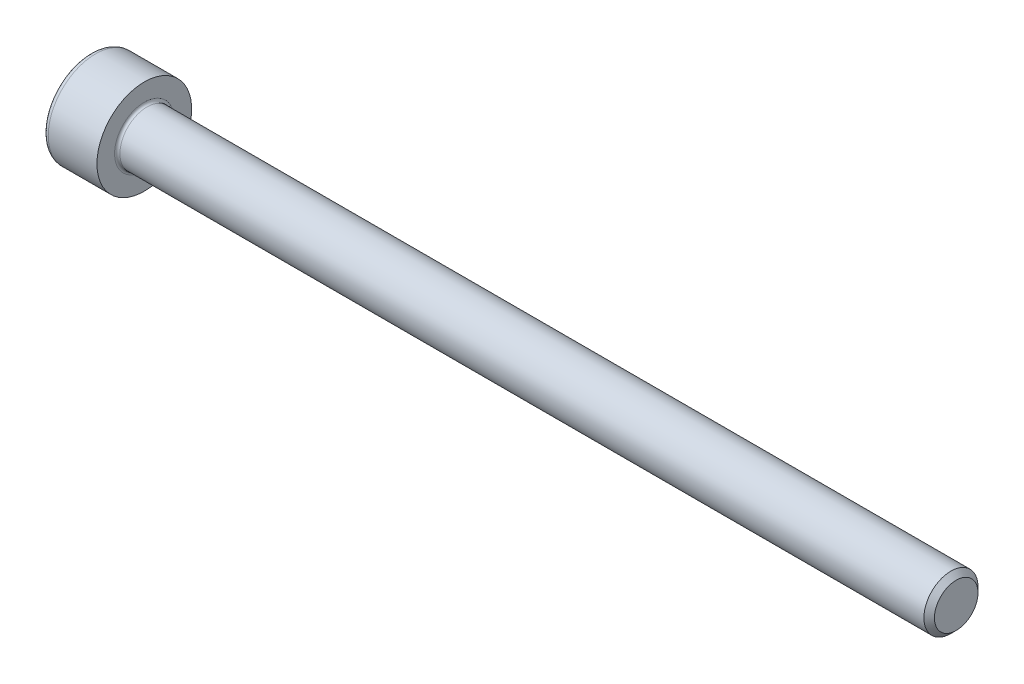
from build123d import *

# Parameters (mm, degrees)
FILLET1_R   = 0.2
FILLET2_R   = 0.4
HEX_2_DEPTH = 2


with BuildPart() as part:
    # BodySke → Base-Revolve (revolve)
    with BuildSketch(Plane.XY):
        Polygon((0, 0), (0, 3.5), (4, 3.5), (4, 2), (63.61, 2), (64, 1.61), (64, 0), align=None)
    revolve(axis=Axis((-31.75, 0, 0), (1, 0, 0)))

    # Fillet1
    fillet1_edges = [part.edges().sort_by_distance(p)[0] for p in [
        (4, -2, 0),
    ]]
    fillet(fillet1_edges, radius=FILLET1_R)

    # Fillet2
    fillet2_edges = [part.edges().sort_by_distance(p)[0] for p in [
        (0, -3.5, 0),
    ]]
    fillet(fillet2_edges, radius=FILLET2_R)

    # Sketch2 → Hex-PreBroach (revolve, cut)
    with BuildSketch(Plane.XY):
        Polygon((0, 1.51), (2, 1.51), (2.871798906, 0), (0, 0), align=None)
    revolve(axis=Axis((0, 0, 0), (1, 0, 0)), mode=Mode.SUBTRACT)

    # Sketch3 → Hex 2 (cut)
    with BuildSketch(Plane(origin=(0, 0, 0), x_dir=(0, 0.5, 0.866025404), z_dir=(-1, 0, 0))):
        Polygon((0.871798906, 1.51), (-0.871798906, 1.51), (-1.743597813, 0), (-0.871798906, -1.51), (0.871798906, -1.51), (1.743597813, 0), align=None)
    extrude(amount=-HEX_2_DEPTH, mode=Mode.SUBTRACT)


solid = part.part
